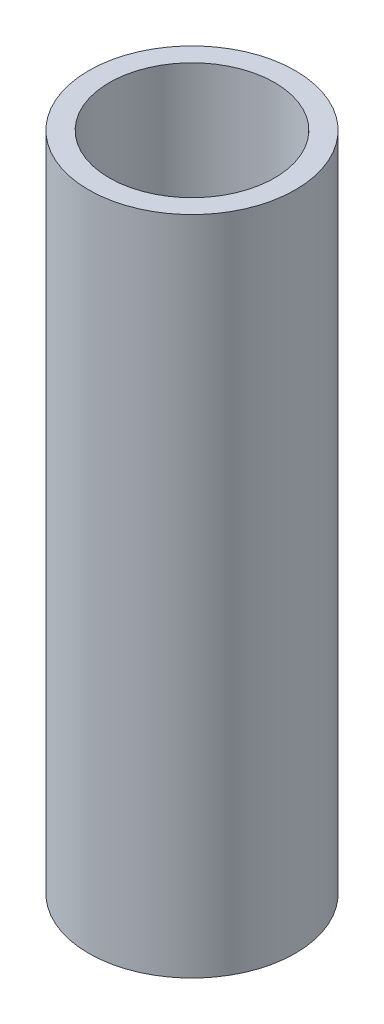
from build123d import *

# Parameters (mm, degrees)
CROQUIS1_R              = 12.5
CROQUIS1_R_2            = 10
SALIENTE_EXTRUIR1_DEPTH = 40


with BuildPart() as part:
    # Croquis1 → Saliente-Extruir1 (new body, symmetric)
    with BuildSketch(Plane(origin=(0, 0, 0), x_dir=(1, 0, 0), z_dir=(0, 1, 0))):
        Circle(CROQUIS1_R)
        Circle(CROQUIS1_R_2, mode=Mode.SUBTRACT)
    extrude(amount=SALIENTE_EXTRUIR1_DEPTH, both=True)


solid = part.part
